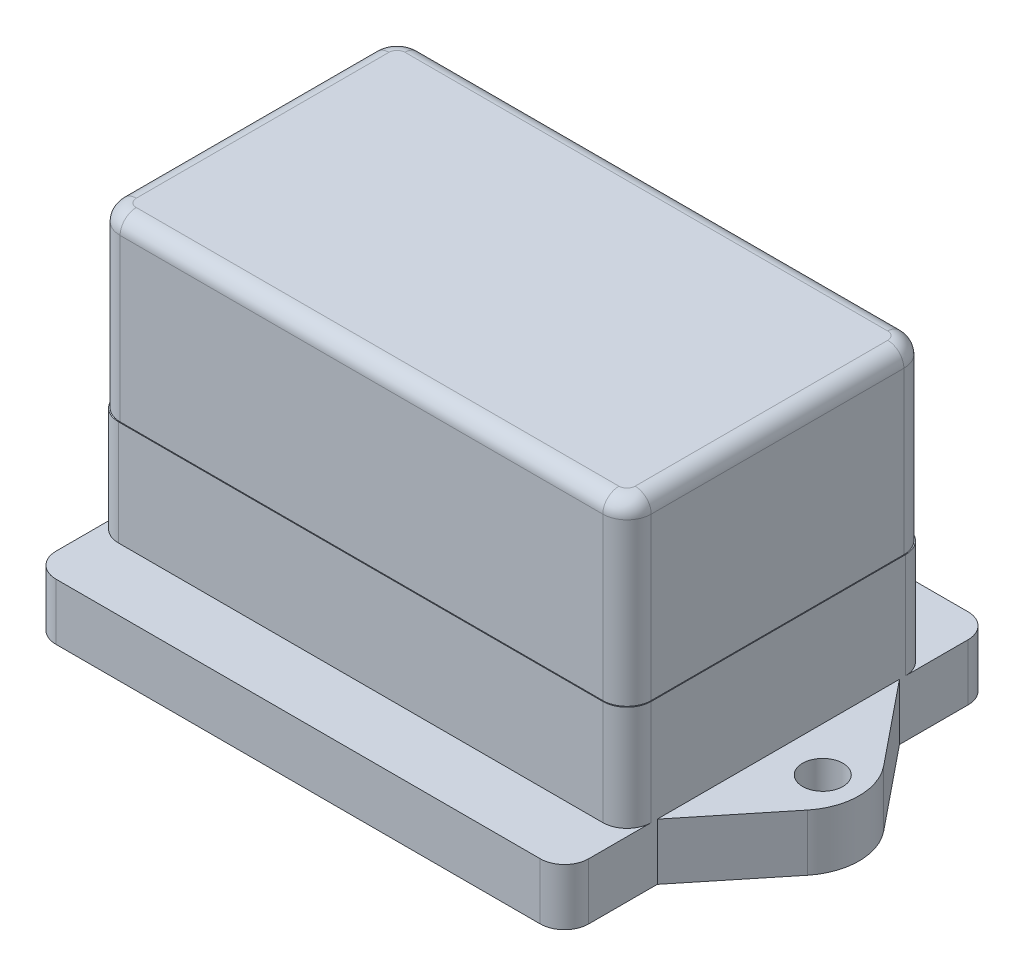
from build123d import *

# Parameters (mm, degrees)
BOSS_EXTRUDE1_DEPTH       = 7
F_5_0MM_DOWEL_HOLE1_D     = 5
F_5_0MM_DOWEL_HOLE1_DEPTH = 7
SKETCH4_W                 = 66
SKETCH4_H                 = 37.5
BOSS_EXTRUDE2_DEPTH       = 13
SKETCH5_W                 = 65.8
SKETCH5_H                 = 37.3
BOSS_EXTRUDE3_DEPTH       = 22
FILLET1_R                 = 3
FILLET2_R                 = 2


with BuildPart() as part:
    # Sketch1 → Boss-Extrude1 (new body)
    with BuildSketch(Plane(origin=(0, 0, 0), x_dir=(1, 0, 0), z_dir=(0, 1, 0))):
        with BuildLine():
            Line((-41.327503189, 4.721250532), (-33, 15))
            Line((-33, 15), (-33, 26.5))
            Line((-33, 26.5), (33, 26.5))
            Line((33, 26.5), (33, 15))
            Line((33, 15), (41.327503189, 4.721250532))
            ThreePointArc((41.327503189, 4.721250532), (43, 0), (41.327503189, -4.721250532))
            Line((41.327503189, -4.721250532), (33, -15))
            Line((33, -15), (33, -26.5))
            Line((33, -26.5), (-33, -26.5))
            Line((-33, -26.5), (-33, -15))
            Line((-33, -15), (-41.327503189, -4.721250532))
            ThreePointArc((-41.327503189, -4.721250532), (-43, 0), (-41.327503189, 4.721250532))
        make_face()
    extrude(amount=BOSS_EXTRUDE1_DEPTH)

    # Ø5.0mm Dowel Hole1
    with Locations(Plane(origin=(0, 7, 0), x_dir=(1, 0, 0), z_dir=(0, 1, 0))):
        with Locations((-38.5, 0), (38.5, 0)):
            Hole(F_5_0MM_DOWEL_HOLE1_D / 2, depth=F_5_0MM_DOWEL_HOLE1_DEPTH)

    # Sketch4 → Boss-Extrude2 (add)
    with BuildSketch(Plane(origin=(0, 7, 0), x_dir=(1, 0, 0), z_dir=(0, 1, 0))):
        Rectangle(SKETCH4_W, SKETCH4_H)
    extrude(amount=BOSS_EXTRUDE2_DEPTH)

    # Sketch5 → Boss-Extrude3 (add)
    with BuildSketch(Plane(origin=(0, 20, 0), x_dir=(1, 0, 0), z_dir=(0, 1, 0))):
        Rectangle(SKETCH5_W, SKETCH5_H)
    extrude(amount=BOSS_EXTRUDE3_DEPTH)

    # Fillet1
    fillet1_edges = [part.edges().sort_by_distance(p)[0] for p in [
        (-33, 3.5, -26.5),
        (33, 3.5, -26.5),
        (33, 3.5, 26.5),
        (-33, 3.5, 26.5),
        (33, 13.5, 18.75),
        (33, 13.5, -18.75),
        (-33, 13.5, -18.75),
        (-33, 13.5, 18.75),
        (32.9, 31, 18.65),
        (32.9, 31, -18.65),
        (-32.9, 31, -18.65),
        (-32.9, 31, 18.65),
    ]]
    fillet(fillet1_edges, radius=FILLET1_R)

    # Fillet2
    fillet2_edges = [part.edges().sort_by_distance(p)[0] for p in [
        (32.9, 42, 0),
        (0, 42, 18.65),
        (0, 42, -18.65),
        (-32.9, 42, 0),
        (-32.021320344, 42, 17.771320344),
        (-32.021320344, 42, -17.771320344),
        (32.021320344, 42, -17.771320344),
        (32.021320344, 42, 17.771320344),
    ]]
    fillet(fillet2_edges, radius=FILLET2_R)


solid = part.part
